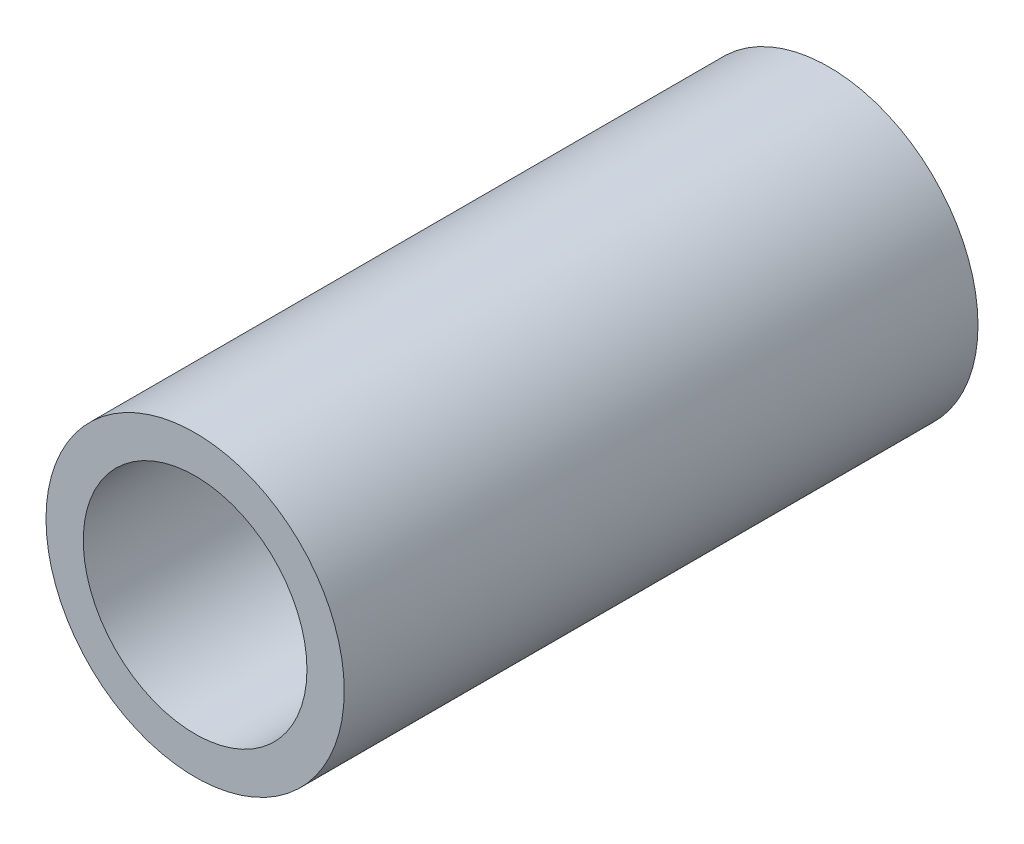
from build123d import *

# Parameters (mm, degrees)
SKETCH_1_R      = 2
SKETCH_1_R_2    = 1.5
EXTRUDE_1_DEPTH = 8.5


with BuildPart() as part:
    # ｽｹｯﾁ1 → ﾎﾞｽ - 押し出し1 (new body)
    with BuildSketch(Plane.XY):
        Circle(SKETCH_1_R)
        Circle(SKETCH_1_R_2, mode=Mode.SUBTRACT)
    extrude(amount=EXTRUDE_1_DEPTH)


solid = part.part
